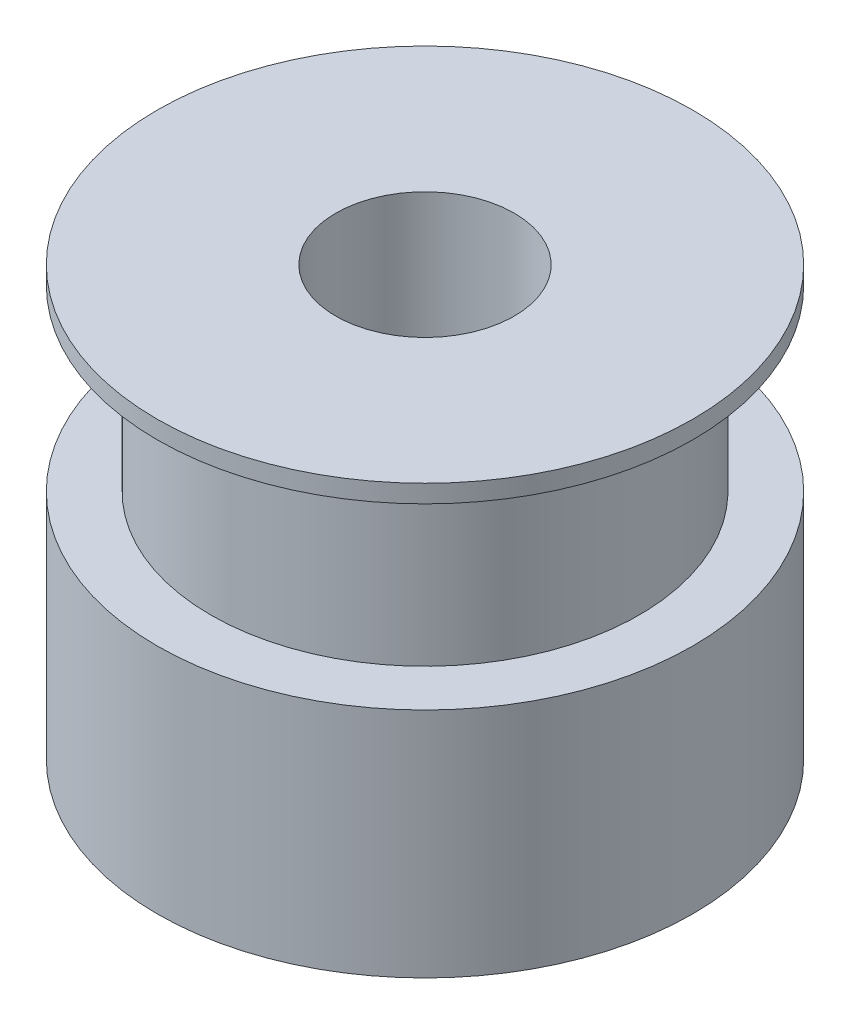
from build123d import *


with BuildPart() as part:
    # Sketch1 → Revolve1 (revolve)
    with BuildSketch(Plane.XY):
        Polygon((-2.5, -12), (-2.5, 0), (-7.5, 0), (-7.5, -0.5), (-6, -0.5), (-6, -5.5), (-7.5, -5.5), (-7.5, -12), align=None)
    revolve(axis=Axis((0, -5.596510299, 0), (0, 1, 0)))


solid = part.part
